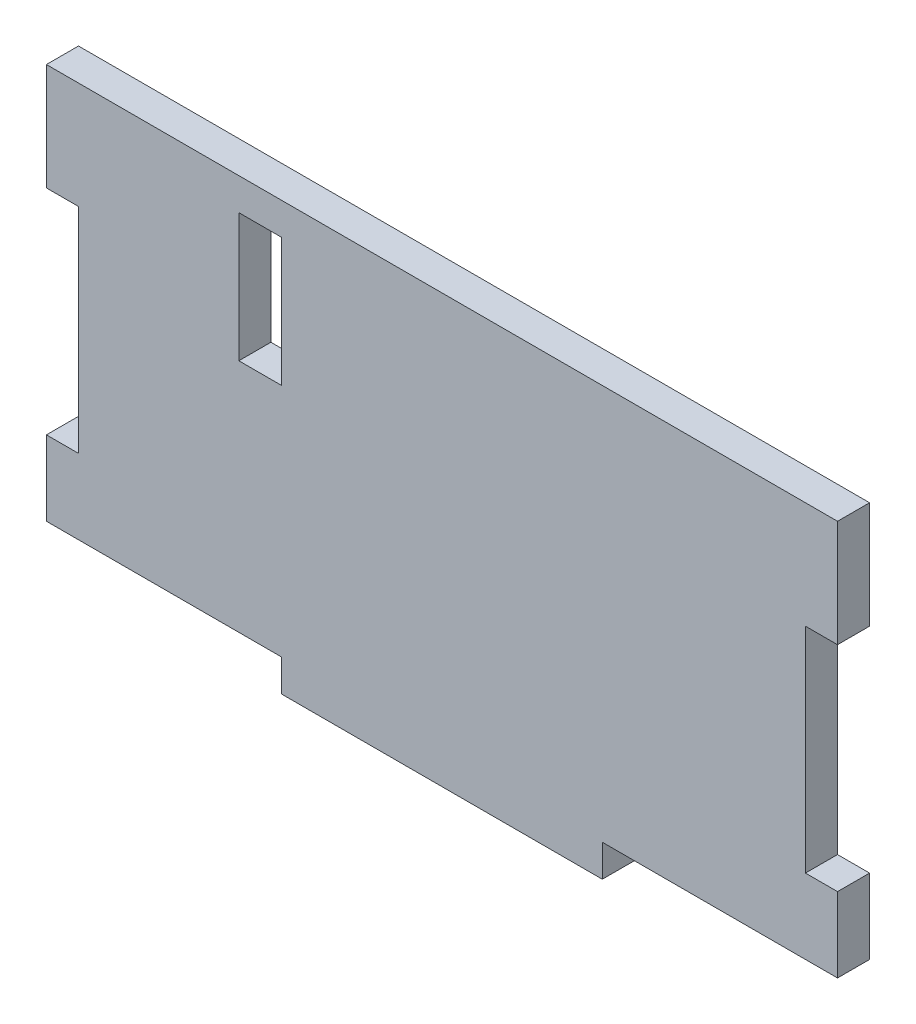
from build123d import *

# Parameters (mm, degrees)
ESBO_O1_W                = 74
ESBO_O1_H                = 40
RESSALTO_EXTRUS_O1_DEPTH = 3
ESBO_O2_W                = 22
ESBO_O2_H                = 3
ESBO_O2_W_2              = 3
ESBO_O2_H_2              = 20
CORTE_EXTRUS_O1_DEPTH    = 3
ESBO_O3_W                = 4
ESBO_O3_H                = 12
CORTE_EXTRUS_O2_DEPTH    = 10


with BuildPart() as part:
    # Esboço1 → Ressalto-extrusão1 (new body)
    with BuildSketch(Plane.XY):
        Rectangle(ESBO_O1_W, ESBO_O1_H)
    extrude(amount=RESSALTO_EXTRUS_O1_DEPTH)

    # Esboço2 → Corte-extrusão1 (cut)
    with BuildSketch(Plane.XY.offset(3)):
        with Locations((-26, -18.5)):
            Rectangle(ESBO_O2_W, ESBO_O2_H)
        with Locations((26, -18.5)):
            Rectangle(ESBO_O2_W, ESBO_O2_H)
        with Locations((-35.5, 0)):
            Rectangle(ESBO_O2_W_2, ESBO_O2_H_2)
        with Locations((35.5, 0)):
            Rectangle(ESBO_O2_W_2, ESBO_O2_H_2)
    extrude(amount=-CORTE_EXTRUS_O1_DEPTH, mode=Mode.SUBTRACT)

    # Esboço3 → Corte-extrusão2 (cut)
    with BuildSketch(Plane.XY.offset(3)):
        with Locations((-17, 11)):
            Rectangle(ESBO_O3_W, ESBO_O3_H)
    extrude(amount=-CORTE_EXTRUS_O2_DEPTH, mode=Mode.SUBTRACT)


solid = part.part
